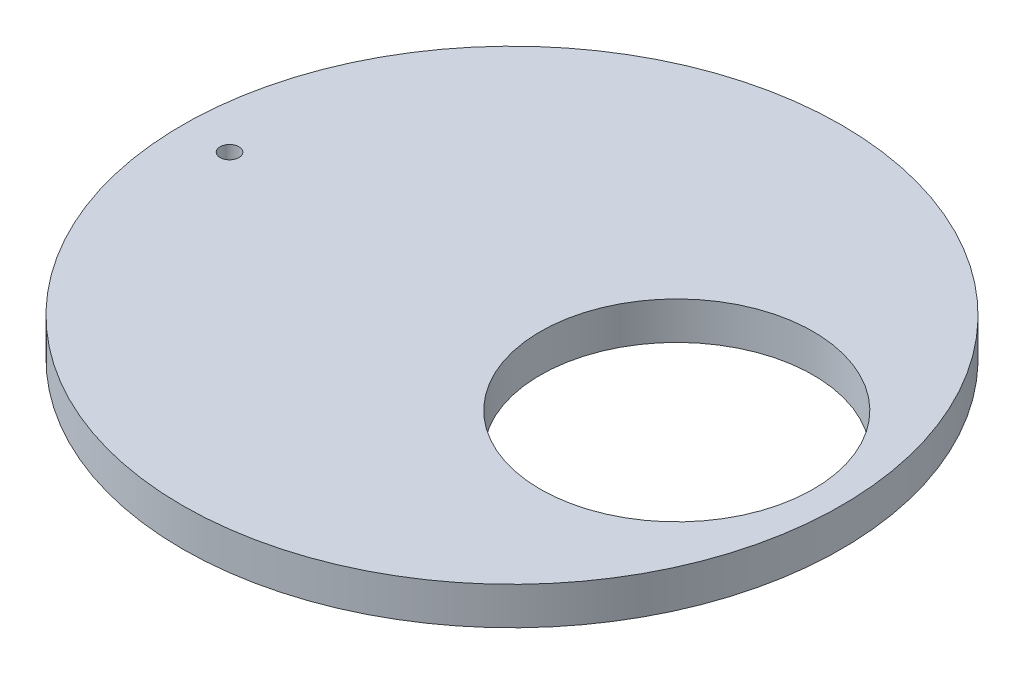
from build123d import *

# Parameters (mm, degrees)
SKETCH1_R           = 70
BOSS_EXTRUDE1_DEPTH = 8
CUT_EXTRUDE1_REACH  = 10
SKETCH2_R           = 2
SKETCH3_R           = 2.4
CUT_EXTRUDE2_DEPTH  = 2


with BuildPart() as part:
    # Sketch1 → Boss-Extrude1 (new body)
    with BuildSketch(Plane(origin=(0, 0, 0), x_dir=(1, 0, 0), z_dir=(0, 1, 0))):
        Circle(SKETCH1_R)
        with BuildLine():
            ThreePointArc((35, -29), (6, 0), (35, 29))
            ThreePointArc((35, 29), (55.506096654, 20.506096654), (64, 0))
            ThreePointArc((64, 0), (55.506096654, -20.506096654), (35, -29))
        make_face(mode=Mode.SUBTRACT)
    extrude(amount=BOSS_EXTRUDE1_DEPTH)

    # Sketch2 → Cut-Extrude1 (cut, up to next)
    with BuildSketch(Plane(origin=(0, 8, 0), x_dir=(1, 0, 0), z_dir=(0, 1, 0)), mode=Mode.PRIVATE) as cut_extrude1_sk1:
        with Locations((-59.999999981, -0.001490332)):
            Circle(SKETCH2_R)
    cut_extrude1_tool1 = extrude(cut_extrude1_sk1.sketch, amount=-CUT_EXTRUDE1_REACH, mode=Mode.PRIVATE) & part.part
    add(cut_extrude1_tool1.solids().sort_by_distance((-60, 8, 0.00149))[0], mode=Mode.SUBTRACT)

    # Sketch3 → Cut-Extrude2 (cut)
    with BuildSketch(Plane.XZ):
        with Locations((-59.999999981, 0.001490332)):
            Circle(SKETCH3_R)
    extrude(amount=-CUT_EXTRUDE2_DEPTH, mode=Mode.SUBTRACT)


solid = part.part
